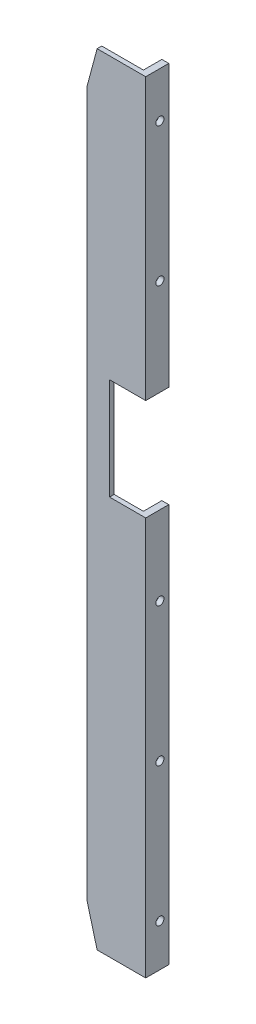
from build123d import *

# Parameters (mm, degrees)
EXTRUDE1_DEPTH          = 50.8
SKETCH3_W               = 60
SKETCH3_H               = 98.6
CUT_EXTRUDE1_DEPTH      = 48.5
CUT_EXTRUDE1_DEPTH_BACK = 650.5
EXTRUDE2_DEPTH          = 253.5
EXTRUDE2_DEPTH_BACK     = 253.5
EXTRUDE8_DEPTH          = 75
SKETCH4_W               = 30
SKETCH4_H               = 66
CUT_EXTRUDE2_DEPTH      = 46
LPATTERN1_COUNT         = 6
LPATTERN1_PITCH         = 90
SKETCH10_R              = 2.25
EXTRUDE7_DEPTH          = 102.6
SKETCH13_W              = 158
SKETCH13_H              = 135
SKETCH13_W_2            = 38
SKETCH13_H_2            = 15
EXTRUDE10_DEPTH         = 100
EXTRUDE10_DEPTH_BACK    = 700


with BuildPart() as part:
    # Sketch2 → Extrude1 (new body, symmetric)
    with BuildSketch(Plane.XY):
        Polygon((168.229133429, 47.5), (168.229133429, -47.5), (159.029133429, -81.83486743), (159.029133429, -520.16513257), (168.229133429, -554.5), (168.229133429, -649.5), (204.029133429, -649.5), (204.029133429, 47.5), align=None)
    extrude(amount=EXTRUDE1_DEPTH, both=True)

    # Sketch3 → Cut-Extrude1 (cut, two sides)
    with BuildSketch(Plane(origin=(0, 0, 0), x_dir=(1, 0, 0), z_dir=(0, 1, 0))) as cut_extrude1_sk:
        with Locations((172.529133429, 0)):
            Rectangle(SKETCH3_W, SKETCH3_H)
    extrude(amount=CUT_EXTRUDE1_DEPTH, mode=Mode.SUBTRACT)
    extrude(cut_extrude1_sk.sketch, amount=-CUT_EXTRUDE1_DEPTH_BACK, mode=Mode.SUBTRACT)


with BuildPart() as body_2:
    # Sketch5 → Extrude2 (new body, two sides)
    with BuildSketch(Plane(origin=(0, -301, 0), x_dir=(1, 0, 0), z_dir=(0, 1, 0))) as extrude2_sk:
        Polygon((198.029133429, 13.4125), (202.529133429, 13.4125), (202.529133429, -1.5875), (164.529133429, -1.5875), (164.529133429, 1.4125), (198.029133429, 1.4125), align=None)
    extrude(amount=EXTRUDE2_DEPTH)
    extrude(extrude2_sk.sketch, amount=-EXTRUDE2_DEPTH_BACK)

    # Sketch11 → Extrude8 (cut, symmetric)
    with BuildSketch(Plane.XY):
        Polygon((170.973907148, -47.5), (153.959133429, -111), (130.029133429, -111), (130.029133429, -11), (170.973907148, -11), align=None)
        Polygon((153.959133429, -491), (130.029133429, -491), (130.029133429, -591), (170.973907148, -591), (170.973907148, -554.5), align=None)
    extrude(amount=EXTRUDE8_DEPTH, both=True, mode=Mode.SUBTRACT)


with BuildPart() as cut_extrude2_tool:
    # Sketch4 → Cut-Extrude2 (new body, symmetric)
    with BuildSketch(Plane.XY):
        with Locations((194.029133429, -262.7)):
            Rectangle(SKETCH4_W, SKETCH4_H)
    extrude(amount=CUT_EXTRUDE2_DEPTH, both=True)


with BuildPart() as part_1:
    add(part.part)

    # Cut-Extrude2: cut by cut_extrude2_tool
    add(cut_extrude2_tool.part, mode=Mode.SUBTRACT)


with BuildPart() as body_2_1:
    add(body_2.part)

    # Cut-Extrude2: cut by cut_extrude2_tool
    add(cut_extrude2_tool.part, mode=Mode.SUBTRACT)


with BuildPart() as tapped_hole_for_8_32_helicoil1_tool:
    # Sketch34 → Tapped Hole for #8-32 Helicoil1 (revolve)
    with BuildSketch(Plane(origin=(204.029133429, -77.011124935, -7.640243296), x_dir=(0, 0, -1), z_dir=(0, 1, 0))):
        Polygon((0, 0), (0, 45), (2.1971, 45), (2.1971, 5), (2.63779, 5), (2.63779, 0), align=None)
    tapped_hole_for_8_32_helicoil1 = revolve(axis=Axis((210.379133429, -77.011124935, -7.640243296), (-1, 0, 0)))


with BuildPart() as part_2:
    add(part_1.part)

    # Tapped Hole for #8-32 Helicoil1: cut by tapped_hole_for_8_32_helicoil1_tool
    add(tapped_hole_for_8_32_helicoil1_tool.part, mode=Mode.SUBTRACT)


with BuildPart() as body_2_2:
    add(body_2_1.part)

    # Tapped Hole for #8-32 Helicoil1: cut by tapped_hole_for_8_32_helicoil1_tool
    add(tapped_hole_for_8_32_helicoil1_tool.part, mode=Mode.SUBTRACT)


with BuildPart() as lpattern1_tool:
    # LPattern1: Tapped Hole for #8-32 Helicoil1 ×6, 1 skipped
    with Locations(*[(0, -i * LPATTERN1_PITCH, 0) for i in range(1, LPATTERN1_COUNT) if i not in (2,)]):
        add(tapped_hole_for_8_32_helicoil1)


with BuildPart() as part_3:
    add(part_2.part)

    # LPattern1: cut by lpattern1_tool
    add(lpattern1_tool.part, mode=Mode.SUBTRACT)

    # Sketch10 → Extrude7 (cut, through all)
    with BuildSketch(Plane.XY.offset(50.8)):
        with Locations((192.854133429, -102.5)):
            Circle(SKETCH10_R)
        with Locations((192.854133429, -117.5)):
            Circle(SKETCH10_R)
        with Locations((192.854133429, -327.5)):
            Circle(SKETCH10_R)
        with Locations((192.854133429, -312.5)):
            Circle(SKETCH10_R)
        with Locations((192.854133429, -42.5)):
            Circle(SKETCH10_R)
        with Locations((192.854133429, -27.5)):
            Circle(SKETCH10_R)
        with Locations((192.854133429, -586.5)):
            Circle(SKETCH10_R)
        with Locations((192.854133429, -601.5)):
            Circle(SKETCH10_R)
    extrude(amount=-EXTRUDE7_DEPTH, mode=Mode.SUBTRACT)

    # Sketch13 → Extrude10 (cut, two sides)
    with BuildSketch(Plane(origin=(0, 0, 0), x_dir=(1, 0, 0), z_dir=(0, 1, 0))) as extrude10_sk:
        with Locations((183.529133429, 5.9125)):
            Rectangle(SKETCH13_W, SKETCH13_H)
        with Locations((183.529133429, 5.9125)):
            Rectangle(SKETCH13_W_2, SKETCH13_H_2, mode=Mode.SUBTRACT)
    extrude(amount=EXTRUDE10_DEPTH, mode=Mode.SUBTRACT)
    extrude(extrude10_sk.sketch, amount=-EXTRUDE10_DEPTH_BACK, mode=Mode.SUBTRACT)


with BuildPart() as body_2_3:
    add(body_2_2.part)

    # LPattern1: cut by lpattern1_tool
    add(lpattern1_tool.part, mode=Mode.SUBTRACT)


solid = body_2_3.part
